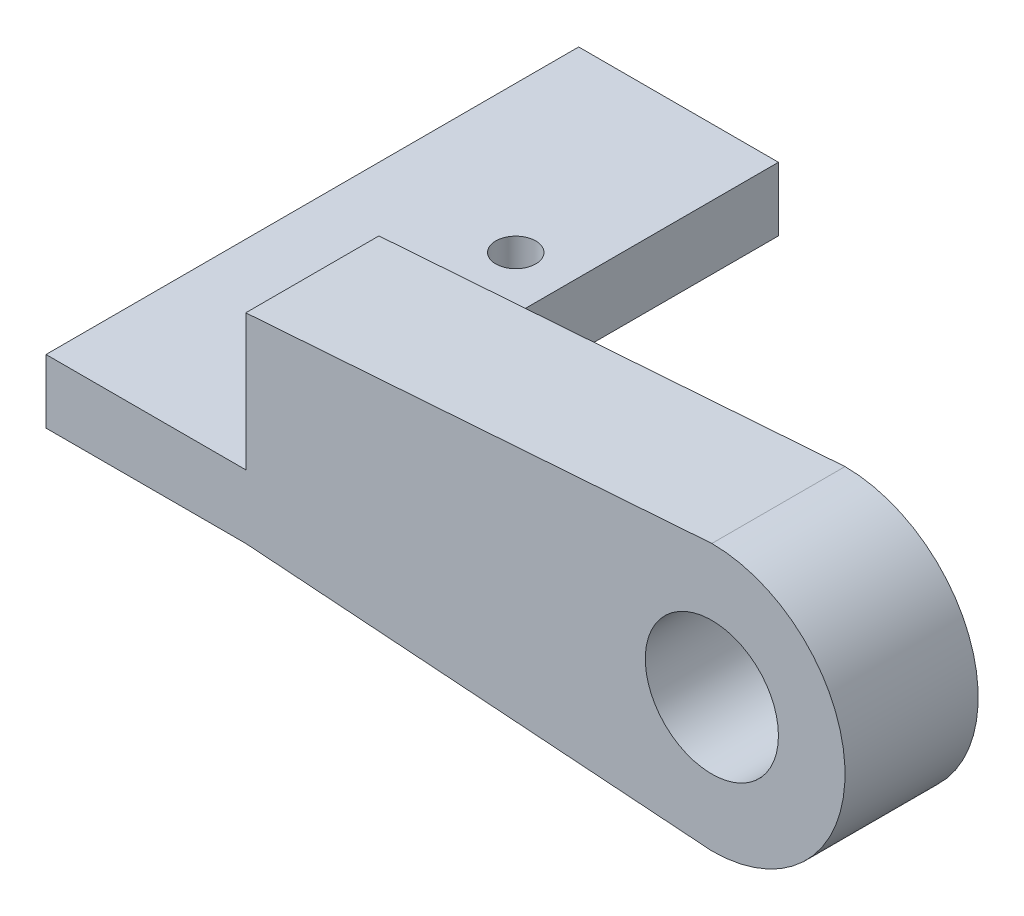
from build123d import *

# Parameters (mm, degrees)
SKETCH1_R           = 5
BOSS_EXTRUDE1_DEPTH = 10
SKETCH3_W           = 10
SKETCH3_H           = 4.789047851
BOSS_EXTRUDE2_DEPTH = 15
SKETCH4_W           = 15
SKETCH4_H           = 4.789047851
BOSS_EXTRUDE3_DEPTH = 30
CUT_EXTRUDE1_REACH  = 9.289
SKETCH5_R           = 1.5


with BuildPart() as part:
    # Sketch1 → Boss-Extrude1 (new body)
    with BuildSketch(Plane.XY):
        with BuildLine():
            Line((0, 10), (-35, 7.5))
            Line((-35, 7.5), (-35, -7.5))
            Line((-35, -7.5), (0, -10))
            ThreePointArc((0, -10), (10, 0), (0, 10))
        make_face()
        Circle(SKETCH1_R, mode=Mode.SUBTRACT)
    extrude(amount=BOSS_EXTRUDE1_DEPTH)

    # Sketch3 → Boss-Extrude2 (add)
    with BuildSketch(Plane.ZY.offset(35)):
        with Locations((5, -5.105476075)):
            Rectangle(SKETCH3_W, SKETCH3_H)
    extrude(amount=BOSS_EXTRUDE2_DEPTH)

    # Sketch4 → Boss-Extrude3 (add)
    with BuildSketch(Plane(origin=(0, 0, 0), x_dir=(-1, 0, 0), z_dir=(0, 0, -1))):
        with Locations((42.5, -5.105476075)):
            Rectangle(SKETCH4_W, SKETCH4_H)
    extrude(amount=BOSS_EXTRUDE3_DEPTH)

    # Sketch5 → Cut-Extrude1 (cut, up to next)
    with BuildSketch(Plane(origin=(0, -2.710952149, 0), x_dir=(1, 0, 0), z_dir=(0, 1, 0)), mode=Mode.PRIVATE) as cut_extrude1_sk1:
        with Locations((-39, 2.273461037)):
            Circle(SKETCH5_R)
    cut_extrude1_tool1 = extrude(cut_extrude1_sk1.sketch, amount=-CUT_EXTRUDE1_REACH, mode=Mode.PRIVATE) & part.part
    add(cut_extrude1_tool1.solids().sort_by_distance((-39, -2.710952, -2.273461))[0], mode=Mode.SUBTRACT)
    # Sketch5 → Cut-Extrude1 (cut, up to next)
    with BuildSketch(Plane(origin=(0, -2.710952149, 0), x_dir=(1, 0, 0), z_dir=(0, 1, 0)), mode=Mode.PRIVATE) as cut_extrude1_sk2:
        with Locations((-39, 14.273461037)):
            Circle(SKETCH5_R)
    cut_extrude1_tool2 = extrude(cut_extrude1_sk2.sketch, amount=-CUT_EXTRUDE1_REACH, mode=Mode.PRIVATE) & part.part
    add(cut_extrude1_tool2.solids().sort_by_distance((-39, -2.710952, -14.273461))[0], mode=Mode.SUBTRACT)


solid = part.part
